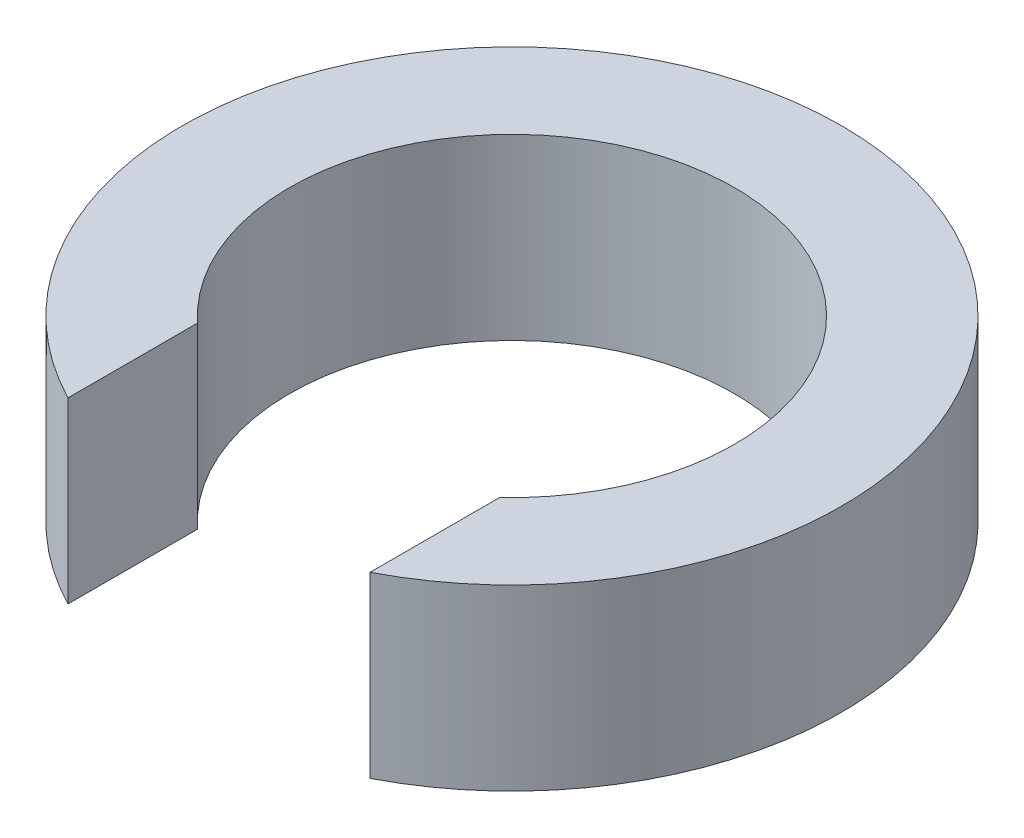
from build123d import *

# Parameters (mm, degrees)
BOSS_EXTRUDE1_DEPTH = 3.25


with BuildPart() as part:
    # Sketch1 → Boss-Extrude1 (new body)
    with BuildSketch(Plane(origin=(0, 0, 0), x_dir=(1, 0, 0), z_dir=(0, 1, 0))):
        with BuildLine():
            Line((-2.75, -2.973213749), (-2.75, -5.332682252))
            ThreePointArc((-2.75, -5.332682252), (0, 6), (2.75, -5.332682252))
            Line((2.75, -5.332682252), (2.75, -2.973213749))
            ThreePointArc((2.75, -2.973213749), (0, 4.05), (-2.75, -2.973213749))
        make_face()
    extrude(amount=BOSS_EXTRUDE1_DEPTH)


solid = part.part
